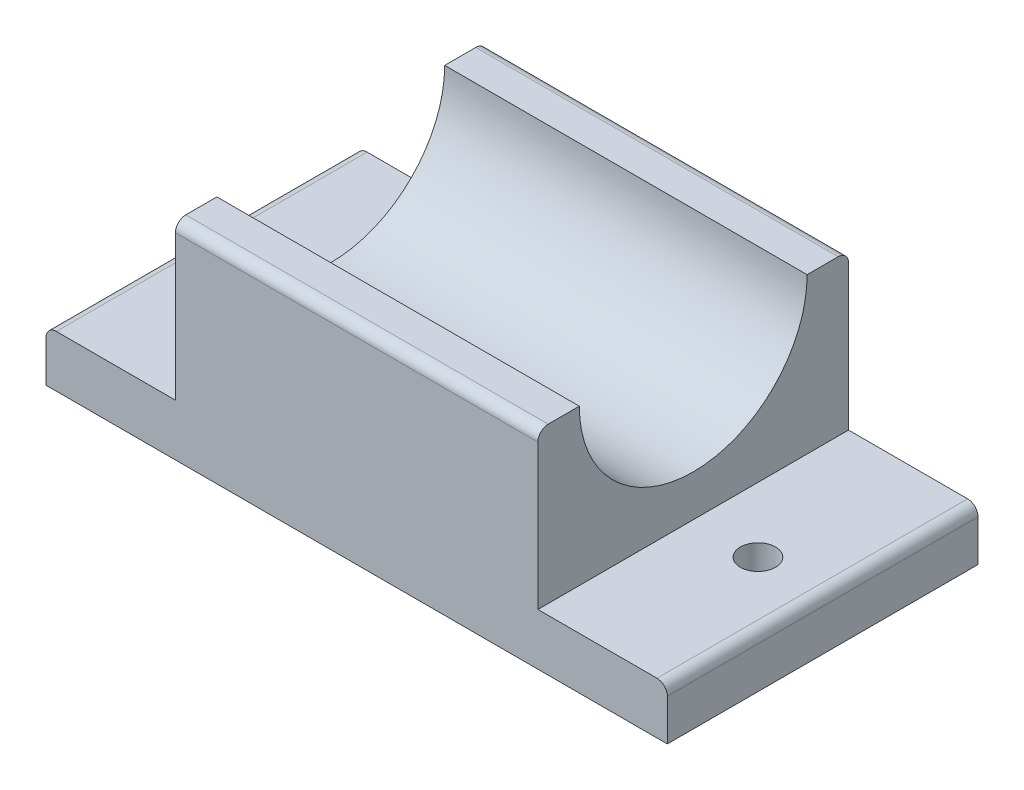
from build123d import *

# Parameters (mm, degrees)
SKETCH1_W            = 60
SKETCH1_H            = 30
BOSS_EXTRUDE1_DEPTH  = 5
SKETCH2_W            = 35
SKETCH2_H            = 30
BOSS_EXTRUDE2_DEPTH  = 15
SKETCH4_R            = 11
CUT_EXTRUDE1_DEPTH   = 48.5
M3_CLEARANCE_HOLE1_D = 3.4
FILLET1_R            = 1
FILLET2_R            = 1
FILLET3_R            = 1
FILLET4_R            = 1


with BuildPart() as part:
    # Sketch1 → Boss-Extrude1 (new body)
    with BuildSketch(Plane(origin=(0, 0, 0), x_dir=(1, 0, 0), z_dir=(0, 1, 0))):
        with Locations((12.386363636, 4.042207792)):
            Rectangle(SKETCH1_W, SKETCH1_H)
    extrude(amount=BOSS_EXTRUDE1_DEPTH)

    # Sketch2 → Boss-Extrude2 (add)
    with BuildSketch(Plane(origin=(0, 5, 0), x_dir=(1, 0, 0), z_dir=(0, 1, 0))):
        with Locations((12.386363636, 4.042207792)):
            Rectangle(SKETCH2_W, SKETCH2_H)
    extrude(amount=BOSS_EXTRUDE2_DEPTH)

    # Sketch4 → Cut-Extrude1 (cut, through all)
    with BuildSketch(Plane(origin=(29.886363636, 0, 0), x_dir=(0, 0, -1), z_dir=(1, 0, 0))):
        with Locations((4.042207792, 20)):
            Circle(SKETCH4_R)
    extrude(amount=-CUT_EXTRUDE1_DEPTH, mode=Mode.SUBTRACT)

    # M3 Clearance Hole1 (through all)
    with Locations(Plane(origin=(0, 5, 0), x_dir=(1, 0, 0), z_dir=(0, 1, 0))):
        with Locations((36.136363636, 4.042207792), (-11.363636364, 4.042207792)):
            Hole(M3_CLEARANCE_HOLE1_D / 2)

    # Fillet1
    fillet1_edges = [part.edges().sort_by_distance(p)[0] for p in [
        (12.386363636, 20, 10.957792208),
    ]]
    fillet(fillet1_edges, radius=FILLET1_R)

    # Fillet2
    fillet2_edges = [part.edges().sort_by_distance(p)[0] for p in [
        (12.386363636, 20, -19.042207792),
    ]]
    fillet(fillet2_edges, radius=FILLET2_R)

    # Fillet3
    fillet3_edges = [part.edges().sort_by_distance(p)[0] for p in [
        (42.386363636, 5, -4.042207792),
    ]]
    fillet(fillet3_edges, radius=FILLET3_R)

    # Fillet4
    fillet4_edges = [part.edges().sort_by_distance(p)[0] for p in [
        (-17.613636364, 5, -4.042207792),
    ]]
    fillet(fillet4_edges, radius=FILLET4_R)


solid = part.part
